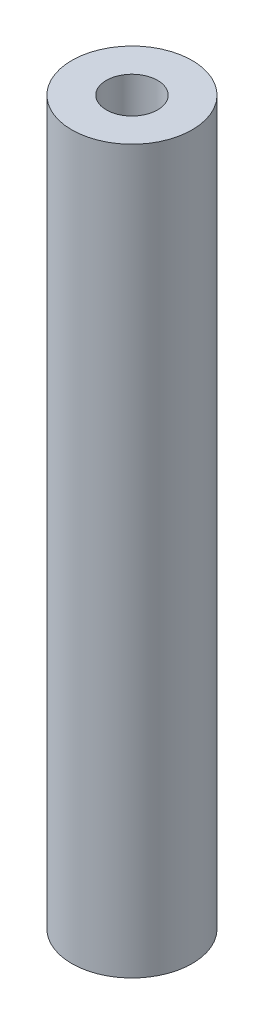
from build123d import *

# Parameters (mm, degrees)
SKETCH1_R                 = 3.175
BOSS_EXTRUDE1_DEPTH       = 38.1
TAP_DRILL_FOR_6_32_TAP1_D = 2.7051


with BuildPart() as part:
    # Sketch1 → Boss-Extrude1 (new body)
    with BuildSketch(Plane(origin=(0, 0, 0), x_dir=(1, 0, 0), z_dir=(0, 1, 0))):
        Circle(SKETCH1_R)
    extrude(amount=BOSS_EXTRUDE1_DEPTH)

    # Tap Drill for #6-32 Tap1 (through all)
    with Locations(Plane(origin=(0, 38.1, 0), x_dir=(1, 0, 0), z_dir=(0, 1, 0))):
        with Locations((0, 0)):
            Hole(TAP_DRILL_FOR_6_32_TAP1_D / 2)


solid = part.part
